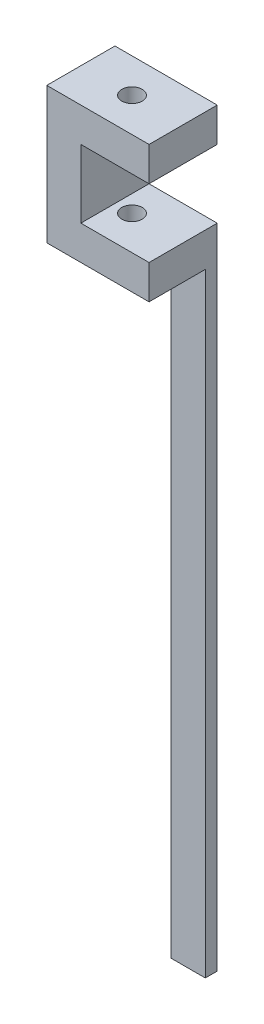
from build123d import *

# Parameters (mm, degrees)
BOSS_EXTRUDE1_DEPTH = 10
SKETCH3_W           = 5
SKETCH3_H           = 1.75
BOSS_EXTRUDE2_DEPTH = 90
SKETCH4_R           = 1.5
CUT_EXTRUDE1_DEPTH  = 111


with BuildPart() as part:
    # Sketch1 → Boss-Extrude1 (new body)
    with BuildSketch(Plane.XY):
        Polygon((0, 10.81190481), (0, -9.18809519), (15, -9.18809519), (15, -4.18809519), (5, -4.18809519), (5, 5.81190481), (15, 5.81190481), (15, 10.81190481), align=None)
    extrude(amount=BOSS_EXTRUDE1_DEPTH)

    # Sketch3 → Boss-Extrude2 (add)
    with BuildSketch(Plane(origin=(0, -9.18809519, 0), x_dir=(-1, 0, 0), z_dir=(0, -1, 0))):
        with Locations((-12.5, -0.875)):
            Rectangle(SKETCH3_W, SKETCH3_H)
    extrude(amount=BOSS_EXTRUDE2_DEPTH)

    # Sketch4 → Cut-Extrude1 (cut, through all)
    with BuildSketch(Plane(origin=(0, 10.81190481, 0), x_dir=(1, 0, 0), z_dir=(0, 1, 0))):
        with Locations((7.5, -5)):
            Circle(SKETCH4_R)
    extrude(amount=-CUT_EXTRUDE1_DEPTH, mode=Mode.SUBTRACT)


solid = part.part
